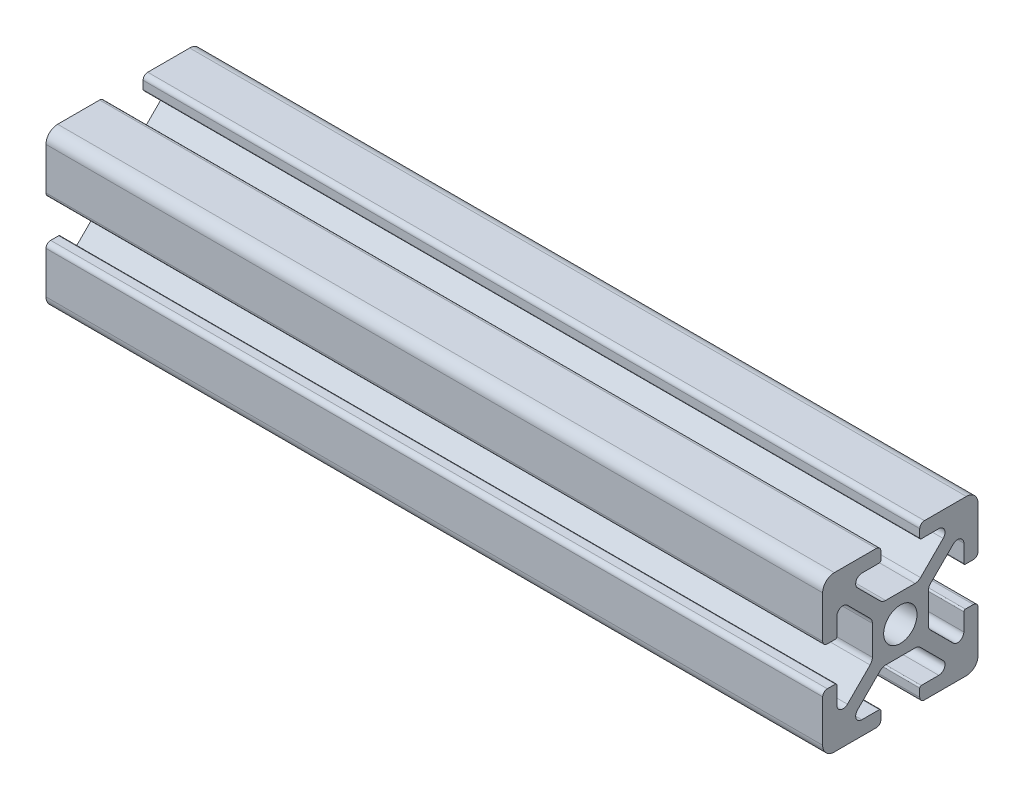
from build123d import *

# Parameters (mm, degrees)
BOSS_EXTRUDE1_DEPTH = 100


with BuildPart() as part:
    # Sketch3 → Boss-Extrude1 (new body)
    with BuildSketch(Plane(origin=(0, 0, 0), x_dir=(0, 0, -1), z_dir=(1, 0, 0))):
        with BuildLine():
            Line((-5.515685425, 6.807463915), (-2.601114729, 3.892893219))
            ThreePointArc((-2.601114729, 3.892893219), (-2.27669138, 3.676120467), (-1.894007948, 3.6))
            Line((-1.894007948, 3.6), (0, 3.6))
            Line((0, 3.6), (0, 2.15))
            ThreePointArc((0, 2.15), (-1.52027958, 1.52027958), (-2.15, 0))
            Line((-2.15, 0), (-3.6, 0))
            Line((-3.6, 0), (-3.6, 1.894007948))
            ThreePointArc((-3.6, 1.894007948), (-3.676120467, 2.27669138), (-3.892893219, 2.601114729))
            Line((-3.892893219, 2.601114729), (-6.807463915, 5.515685425))
            ThreePointArc((-6.807463915, 5.515685425), (-7.679296086, 5.689103626), (-8.17314934, 4.95))
            Line((-8.17314934, 4.95), (-8.17314934, 2.7))
            ThreePointArc((-8.17314934, 2.7), (-8.231727984, 2.558578644), (-8.37314934, 2.5))
            Line((-8.37314934, 2.5), (-9.4, 2.5))
            ThreePointArc((-9.4, 2.5), (-9.824264069, 2.675735931), (-10, 3.1))
            Line((-10, 3.1), (-10, 8.5))
            ThreePointArc((-10, 8.5), (-9.560660172, 9.560660172), (-8.5, 10))
            Line((-8.5, 10), (-3.1, 10))
            ThreePointArc((-3.1, 10), (-2.675735931, 9.824264069), (-2.5, 9.4))
            Line((-2.5, 9.4), (-2.5, 8.37314934))
            ThreePointArc((-2.5, 8.37314934), (-2.558578644, 8.231727984), (-2.7, 8.17314934))
            Line((-2.7, 8.17314934), (-4.95, 8.17314934))
            ThreePointArc((-4.95, 8.17314934), (-5.689103626, 7.679296086), (-5.515685425, 6.807463915))
        make_face()
    extrude(amount=-BOSS_EXTRUDE1_DEPTH)

    # Mirror1: part across plane


with BuildPart() as part_1:
    add(part.part)
    add(part.part.mirror(Plane.ZX))

    # Mirror2: part across plane


with BuildPart() as part_2:
    add(part_1.part)
    add(part_1.part.mirror(Plane.XY))


solid = part_2.part
